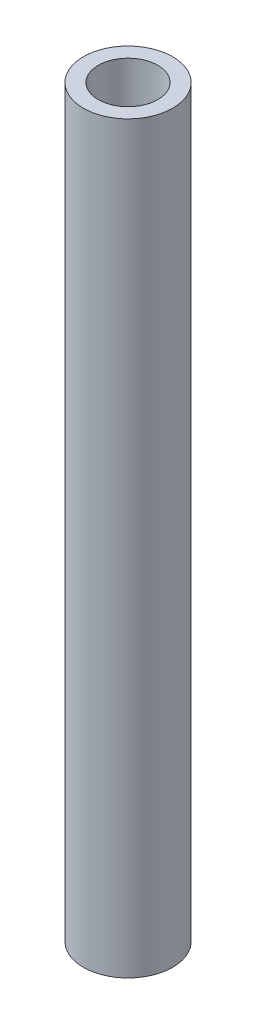
from build123d import *

# Parameters (mm, degrees)
CROQUIS1_W = 1
CROQUIS1_H = 50


with BuildPart() as part:
    # Croquis1 → Revolución1 (revolve)
    with BuildSketch(Plane.XY):
        with Locations((-2.5, 0)):
            Rectangle(CROQUIS1_W, CROQUIS1_H)
    revolve(axis=Axis((0, -0.720216084, 0), (0, 1, 0)))


solid = part.part
